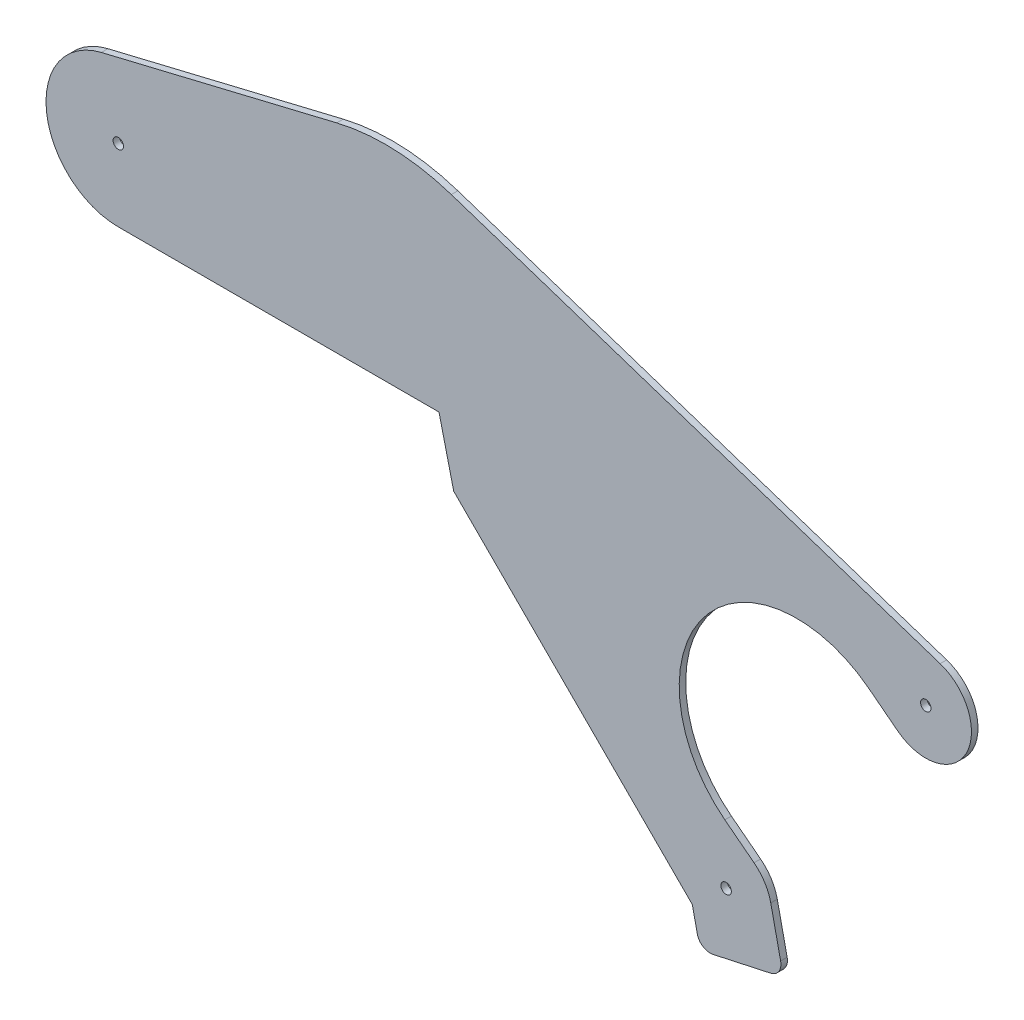
from build123d import *

# Parameters (mm, degrees)
SKETCH1_R           = 2.54
BOSS_EXTRUDE1_DEPTH = 3.175


with BuildPart() as part:
    # Sketch1 → Boss-Extrude1 (new body)
    with BuildSketch(Plane.XY):
        with BuildLine():
            Line((267.156088922, 46.92365038), (279.140387862, 34.939351441))
            Line((279.140387862, 34.939351441), (281.571044282, 23.781894278))
            ThreePointArc((281.571044282, 23.781894278), (284.344053276, 19.790554308), (289.127170298, 18.929064213))
            Line((289.127170298, 18.929064213), (317.240211958, 25.053501369))
            ThreePointArc((317.240211958, 25.053501369), (321.231551928, 27.826510362), (322.093042023, 32.609627384))
            Line((322.093042023, 32.609627384), (317.287210275, 54.669866506))
            ThreePointArc((317.287210275, 54.669866506), (314.35957702, 61.811763931), (309.165828873, 67.521642695))
            Line((309.165828873, 67.521642695), (294.956987541, 78.507489408))
            ThreePointArc((294.956987541, 78.507489408), (284.701481461, 158.676495857), (364.87048791, 168.932001937))
            Line((364.87048791, 168.932001937), (379.079329242, 157.946155224))
            ThreePointArc((379.079329242, 157.946155224), (412.294400675, 165.089560033), (399.659420331, 196.627259288))
            Line((399.659420331, 196.627259288), (161.950324224, 275.333486261))
            ThreePointArc((161.950324224, 275.333486261), (134.2512057, 280.394583932), (106.226730954, 277.658767447))
            Line((106.226730954, 277.658767447), (-8.234725559, 250.092638572))
            ThreePointArc((-8.234725559, 250.092638572), (-34.925, 211.753723054), (0, 180.729739303))
            Line((0, 180.729739303), (91.265902063, 180.729739303))
            Line((91.265902063, 180.729739303), (155.941245852, 180.729739303))
            Line((155.941245852, 180.729739303), (163.107951031, 150.971788271))
            Line((163.107951031, 150.971788271), (267.156088922, 46.92365038))
        make_face()
        with Locations((392.673620981, 175.528699327)):
            Circle(SKETCH1_R, mode=Mode.SUBTRACT)
        with Locations((295.571537134, 49.939098592)):
            Circle(SKETCH1_R, mode=Mode.SUBTRACT)
        with Locations((0, 215.9)):
            Circle(SKETCH1_R, mode=Mode.SUBTRACT)
    extrude(amount=BOSS_EXTRUDE1_DEPTH)


solid = part.part
